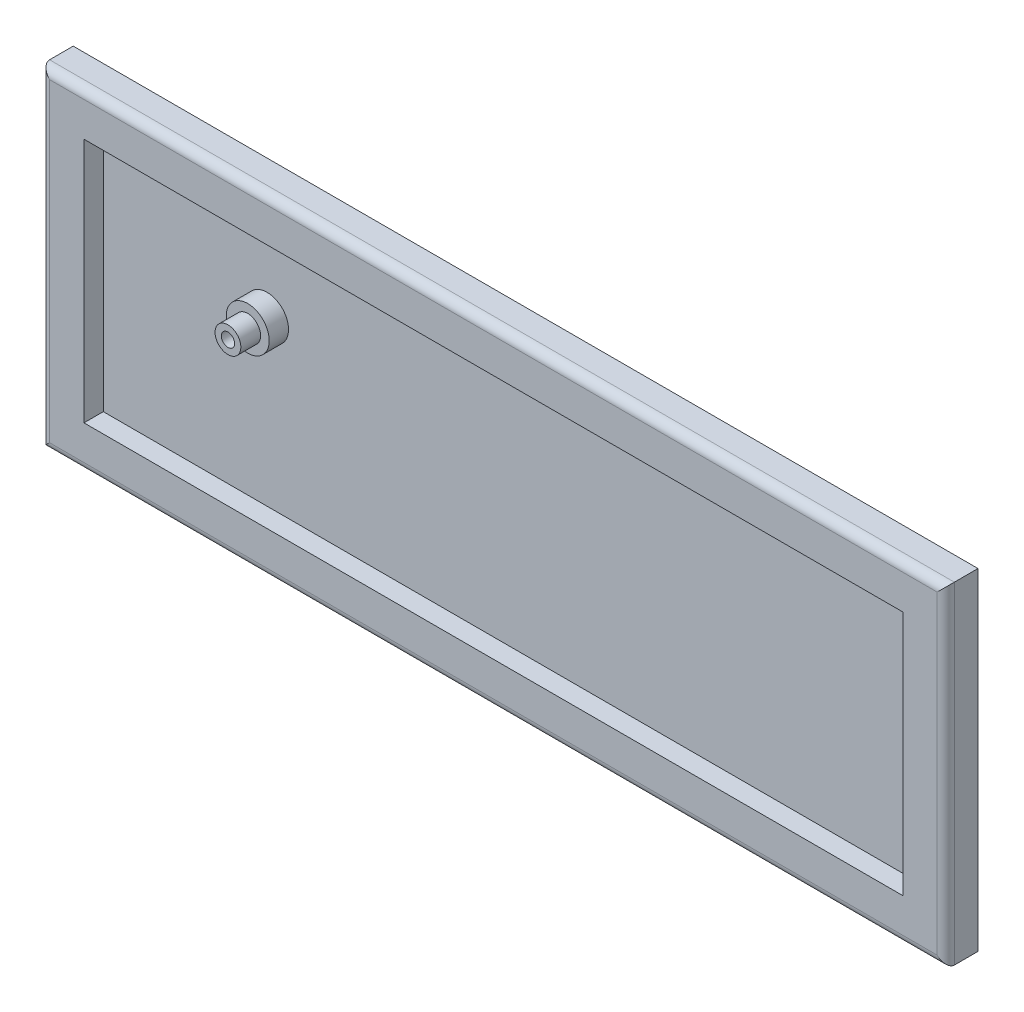
from build123d import *

# Parameters (mm, degrees)
SKETCH_2_W                 = 210.5009
SKETCH_2_H                 = 77.1505
EXTRUDE_1_DEPTH            = 34.5
SHELL_1_T                  = -10
SHELL_1_THICKNESS_2_FACE_W = 190.5009
SHELL_1_THICKNESS_2_FACE_H = 57.1505
SHELL_1_THICKNESS_2_DEPTH  = 7
SKETCH_3_R                 = 2.1
CUT_EXTRUDE_8_DEPTH        = 7.6
SKETCH_4_R                 = 5
EXTRUDE_2_DEPTH            = 9.1
SKETCH_6_R                 = 1.55
CUT_EXTRUDE_9_DEPTH        = 9.1
CUT_EXTRUDE_START          = 12.1
SKETCH_10_OUTSIDE_W        = 257.867
SKETCH_10_OUTSIDE_H        = 124.516
SKETCH_10_OUTSIDE_R        = 3
CUT_EXTRUDE_16_DEPTH       = 4.6
FILLET_1_R                 = 2


with BuildPart() as part:
    # 草图2 → 凸台-拉伸1 (new body)
    with BuildSketch(Plane.XY):
        with Locations((95.3455423, 28.832065)):
            Rectangle(SKETCH_2_W, SKETCH_2_H)
    extrude(amount=EXTRUDE_1_DEPTH)

    # 抽壳1
    shell_1_openings = [part.faces().sort_by_distance(p)[0] for p in [
        (95.3455423, 28.832065, 34.5),
    ]]
    offset(amount=SHELL_1_T, openings=shell_1_openings, kind=Kind.INTERSECTION)

    # 抽壳1 thickness 2 face (on inner face of the shell) → 抽壳1 thickness 2 (cut)
    with BuildSketch(Plane(origin=(95.3455423, 28.832065, 10), x_dir=(-1, 0, 0), z_dir=(0, 0, -1))):
        Rectangle(SHELL_1_THICKNESS_2_FACE_W, SHELL_1_THICKNESS_2_FACE_H)
    extrude(amount=SHELL_1_THICKNESS_2_DEPTH, mode=Mode.SUBTRACT)

    # 草图3 → 切除-拉伸8 (cut)
    with BuildSketch(Plane.XY):
        with Locations(Location((38.19575, 38.357, 0), (0, 0, 180))):
            Circle(SKETCH_3_R)
    extrude(amount=CUT_EXTRUDE_8_DEPTH, mode=Mode.SUBTRACT)

    # 草图4 → 凸台-拉伸2 (add)
    with BuildSketch(Plane.XY.offset(3)):
        with Locations((38.19575, 38.357)):
            Circle(SKETCH_4_R)
    extrude(amount=EXTRUDE_2_DEPTH)

    # 草图6 → 切除-拉伸9 (cut)
    with BuildSketch(Plane.XY.offset(12.1)):
        with Locations((38.19575, 38.357)):
            Circle(SKETCH_6_R)
    extrude(amount=-CUT_EXTRUDE_9_DEPTH, mode=Mode.SUBTRACT)

    # 草图10 outside → 切除-拉伸16 (cut)
    with BuildSketch(Plane.XY.offset(CUT_EXTRUDE_START)):
        with Locations((95.3455, 28.832)):
            Rectangle(SKETCH_10_OUTSIDE_W, SKETCH_10_OUTSIDE_H)
        with Locations((38.19575, 38.357)):
            Circle(SKETCH_10_OUTSIDE_R, mode=Mode.SUBTRACT)
    extrude(amount=-CUT_EXTRUDE_16_DEPTH, mode=Mode.SUBTRACT)


with BuildPart() as cut_extrude_16_kept_piece:
    # of the separate pieces the step leaves, the one the design keeps (cut_extrude_16_pieces_kept)
    add(part.part.solids().sort_by_distance((200.5959923, -9.743185, 0))[0])

    # 圆角1
    fillet_1_edges = [cut_extrude_16_kept_piece.edges().sort_by_distance(p)[0] for p in [
        (-9.9049077, 28.832065, 7.5),
        (95.3455423, -9.743185, 7.5),
        (200.5959923, 28.832065, 7.5),
        (95.3455423, 67.407315, 7.5),
    ]]
    fillet(fillet_1_edges, radius=FILLET_1_R)


solid = cut_extrude_16_kept_piece.part
